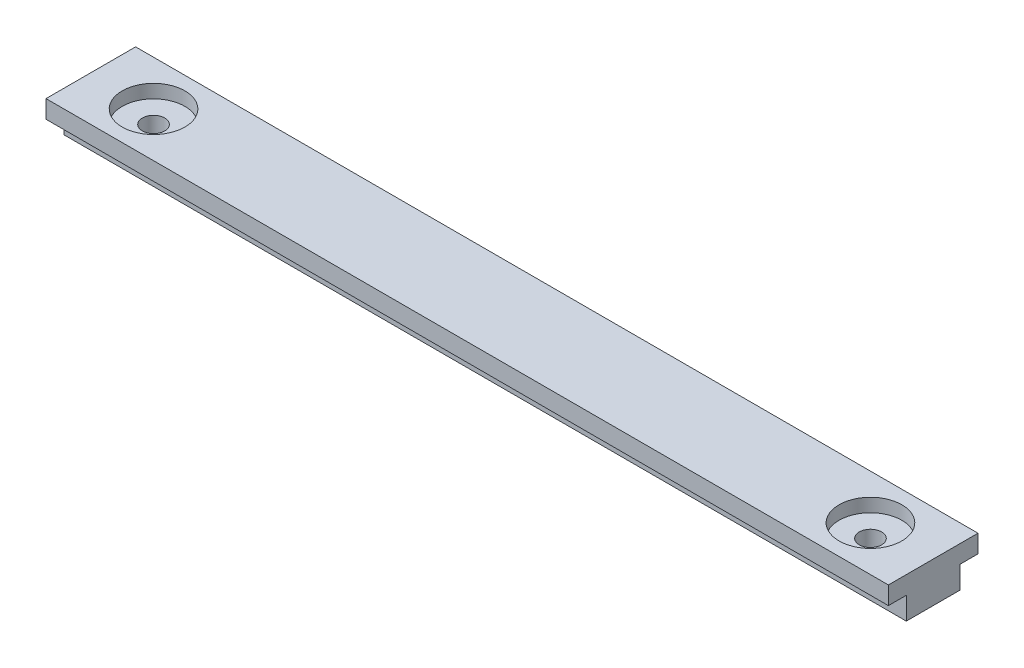
from build123d import *

# Parameters (mm, degrees)
SKETCH1_W          = 94
SKETCH1_H          = 4.5
MAIN_DEPTH         = 5
SKETCH4_W          = 94
SKETCH4_H          = 2.5
WINDOWSLOT1_DEPTH  = 2
SKETCH6_R          = 1.25
CUT_EXTRUDE2_DEPTH = 3
LPATTERN1_COUNT    = 9
LPATTERN1_PITCH    = 10
SKETCH7_R          = 3.5
CUT_EXTRUDE4_DEPTH = 1.5


with BuildPart() as part:
    # Sketch1 → Main (new body, symmetric)
    with BuildSketch(Plane.XY):
        with Locations((0, -2.25)):
            Rectangle(SKETCH1_W, SKETCH1_H)
    extrude(amount=MAIN_DEPTH, both=True)

    # Sketch4 → WindowSlot1 (cut)
    with BuildSketch(Plane.XY.offset(5)):
        with Locations((0, -3.25)):
            Rectangle(SKETCH4_W, SKETCH4_H)
    windowslot1 = extrude(amount=-WINDOWSLOT1_DEPTH, mode=Mode.SUBTRACT)

    # Mirror1: WindowSlot1 across plane
    add(windowslot1.mirror(Plane.XY), mode=Mode.SUBTRACT)

    # Sketch6 → Cut-Extrude2 (cut)
    with BuildSketch(Plane.ZX.offset(-4.5)):
        with Locations((0, 40)):
            Circle(SKETCH6_R)
    cut_extrude2 = extrude(amount=CUT_EXTRUDE2_DEPTH, mode=Mode.SUBTRACT)

    # LPattern1: Cut-Extrude2 ×9
    with Locations(*[(-i * LPATTERN1_PITCH, 0, 0) for i in range(1, LPATTERN1_COUNT)]):
        add(cut_extrude2, mode=Mode.SUBTRACT)

    # Sketch7 → Cut-Extrude4 (cut)
    with BuildSketch(Plane.ZX):
        with Locations((0, 40)):
            Circle(SKETCH7_R)
        with Locations((0, -40)):
            Circle(SKETCH7_R)
    extrude(amount=-CUT_EXTRUDE4_DEPTH, mode=Mode.SUBTRACT)


solid = part.part
